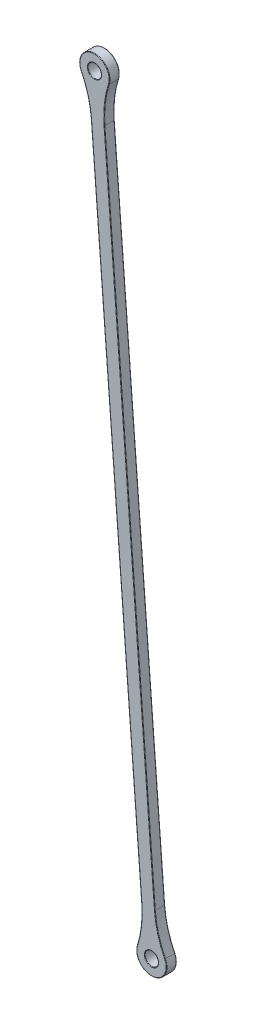
from build123d import *

# Parameters (mm, degrees)
BOSS_EXTRUDE1_DEPTH = 3
FILLET1_R           = 30
FILLET2_R           = 0.15


with BuildPart() as part:
    # Sketch1 → Boss-Extrude1 (new body)
    with BuildSketch(Plane.XY):
        with BuildLine():
            ThreePointArc((12.196400326, 85.365673103), (14.845502434, 77.013283153), (16.184593079, 85.672786378))
            Line((16.184593079, 85.672786378), (16.494096377, 81.653556637))
            ThreePointArc((16.494096377, 81.653556637), (14.653556637, 79.505903623), (12.505903623, 81.346443363))
            Line((12.505903623, 81.346443363), (12.196400326, 85.365673103))
        make_face()
        with BuildLine():
            Line((-0.550690361, 302.998254439), (16.494096377, 81.653556637))
            ThreePointArc((16.494096377, 81.653556637), (14.346443363, 83.494096377), (12.505903623, 81.346443363))
            Line((12.505903623, 81.346443363), (-4.538883114, 302.691141165))
            ThreePointArc((-4.538883114, 302.691141165), (-2.3912301, 300.850601425), (-0.550690361, 302.998254439))
        make_face()
        with BuildLine():
            ThreePointArc((-4.538883114, 302.691141165), (-2.698343375, 304.838794179), (-0.550690361, 302.998254439))
            Line((-0.550690361, 302.998254439), (-0.241187064, 298.979024699))
            ThreePointArc((-0.241187064, 298.979024699), (-2.890289172, 307.331414649), (-4.229379817, 298.671911424))
            Line((-4.229379817, 298.671911424), (-4.538883114, 302.691141165))
        make_face()
    extrude(amount=-BOSS_EXTRUDE1_DEPTH)

    # Fillet1
    fillet1_edges = [part.edges().sort_by_distance(p)[0] for p in [
        (16.184593079, 85.672786378, -1.5),
        (12.196400326, 85.365673103, -1.5),
        (-4.229379817, 298.671911424, -1.5),
        (-0.241187064, 298.979024699, -1.5),
    ]]
    fillet(fillet1_edges, radius=FILLET1_R)

    # Fillet2
    fillet2_edges = [part.edges().sort_by_distance(p)[0] for p in [
        (3.983510255, 192.018792264, 0),
        (3.983510255, 192.018792264, -3),
        (14.845502434, 77.013283153, 0),
        (14.845502434, 77.013283153, -3),
        (12.505903623, 81.346443363, -3),
        (7.971703008, 192.325905538, 0),
        (7.971703008, 192.325905538, -3),
        (-2.890289172, 307.331414649, 0),
        (-2.890289172, 307.331414649, -3),
        (11.407501389, 88.466521567, 0),
        (11.407501389, 88.466521567, -3),
        (16.489440699, 88.857859479, 0),
        (16.489440699, 88.857859479, -3),
        (-4.534227437, 295.486838323, 0),
        (-2.3912301, 300.850601425, -3),
        (-4.534227437, 295.486838323, -3),
        (0.547711873, 295.878176235, 0),
        (0.547711873, 295.878176235, -3),
        (-2.3912301, 300.850601425, 0),
        (12.505903623, 81.346443363, 0),
    ]]
    fillet(fillet2_edges, radius=FILLET2_R)


solid = part.part
